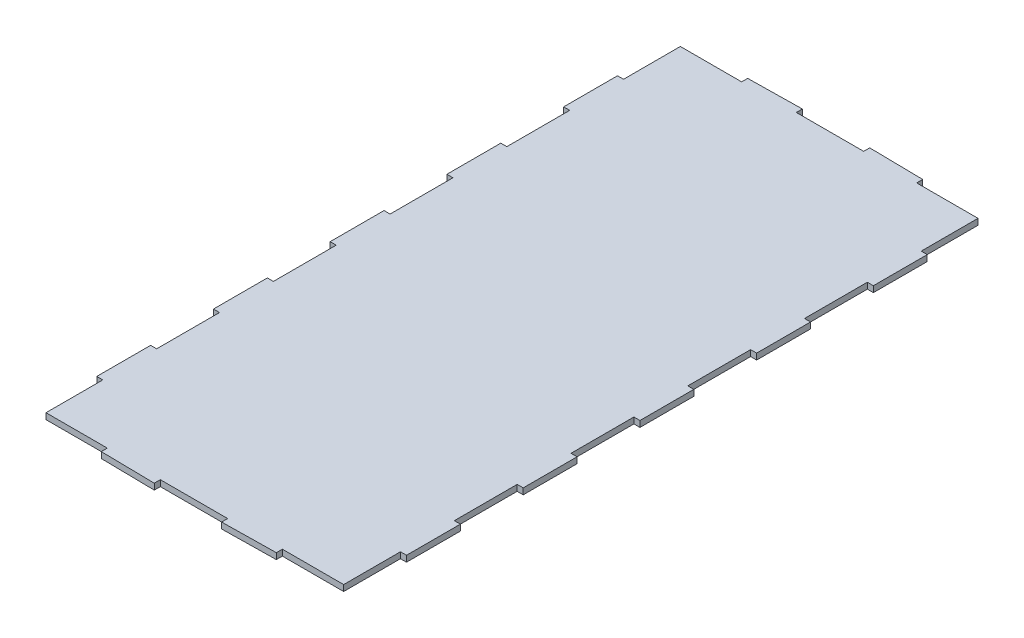
from build123d import *

# Parameters (mm, degrees)
BOSS_EXTRUDE1_DEPTH = 5.7


with BuildPart() as part:
    # Sketch1 → Boss-Extrude1 (new body)
    with BuildSketch(Plane(origin=(0, 0, 0), x_dir=(1, 0, 0), z_dir=(0, 1, 0))):
        Polygon((31.75, 299.891703858), (-31.75, 299.891703858), (-31.75, 305.591703858), (-82.54382924, 304.79992666), (-82.55, 299.09993), (-140.35, 299.09993), (-140.35, 245.5366), (-146.05, 245.5366), (-146.05, 194.7366), (-140.35, 194.7366), (-140.35, 135.47), (-146.05, 135.47), (-146.05, 84.67), (-140.35, 84.67), (-140.35, 25.4), (-146.05, 25.4), (-146.05, -25.4), (-140.35, -25.4), (-140.35, -84.67), (-146.05, -84.67), (-146.05, -135.47), (-140.35, -135.47), (-140.35, -194.7366), (-146.05, -194.7366), (-146.05, -245.5366), (-140.35, -245.5366), (-140.35, -299.09993), (-82.55, -299.09993), (-82.54382924, -304.79992666), (-31.75, -305.591703858), (-31.75, -299.891703858), (31.75, -299.891703858), (31.75, -305.591703858), (82.54382924, -304.79992666), (82.55, -299.09993), (140.35, -299.09993), (140.35, -245.5366), (146.05, -245.5366), (146.05, -194.7366), (140.35, -194.7366), (140.35, -135.47), (146.05, -135.47), (146.05, -84.67), (140.35, -84.67), (140.35, -25.4), (146.05, -25.4), (146.05, 25.4), (140.35, 25.4), (140.35, 84.67), (146.05, 84.67), (146.05, 135.47), (140.35, 135.47), (140.35, 194.7366), (146.05, 194.7366), (146.05, 245.5366), (140.35, 245.5366), (140.35, 299.09993), (82.55, 299.09993), (82.54382924, 304.79992666), (31.75, 305.591703858), align=None)
    extrude(amount=BOSS_EXTRUDE1_DEPTH)


solid = part.part
